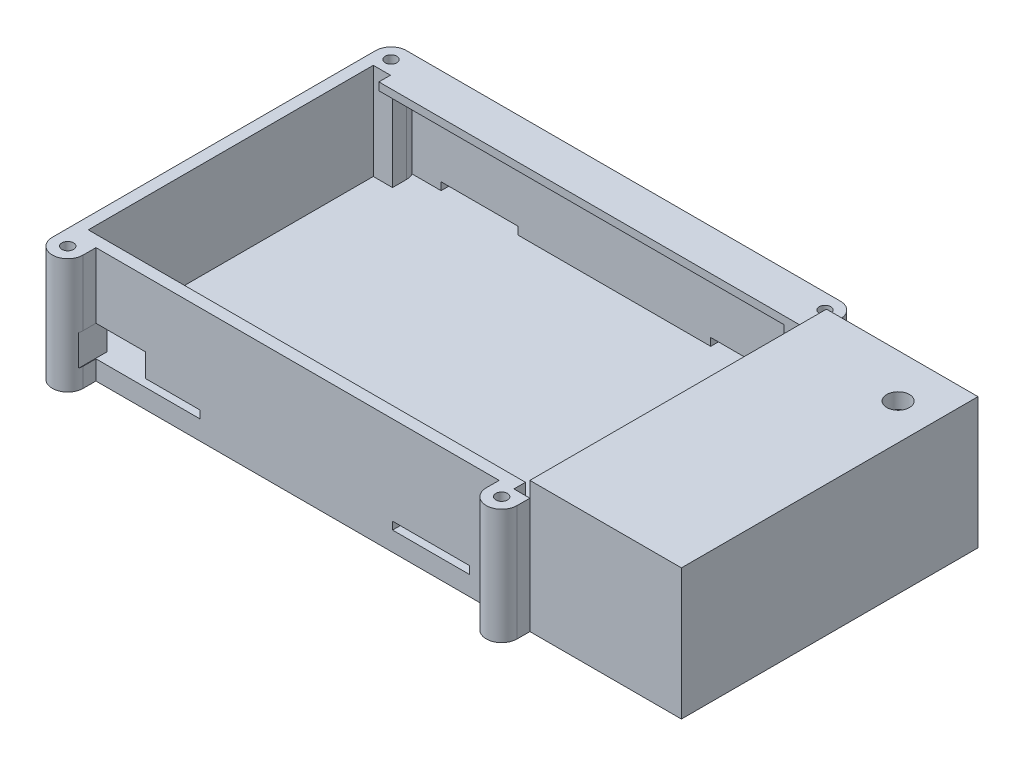
from build123d import *

# Parameters (mm, degrees)
SKETCH1_W           = 160
SKETCH1_H           = 77
BOSS_EXTRUDE1_DEPTH = 5
BOSS_EXTRUDE2_DEPTH = 25
SKETCH3_R           = 1.499999813
SKETCH3_R_2         = 1.5
BOSS_EXTRUDE3_DEPTH = 30
SKETCH5_W           = 39.3418497
SKETCH5_H           = 77
SKETCH5_R           = 2.947381685
BOSS_EXTRUDE5_DEPTH = 4
BOSS_EXTRUDE6_DEPTH = 5
SKETCH9_W           = 112.573012358
SKETCH9_H           = 2
BOSS_EXTRUDE7_DEPTH = 25
CUT_EXTRUDE2_START  = -74
SKETCH7_W           = 13
SKETCH7_H           = 8
CUT_EXTRUDE2_DEPTH  = 119
SKETCH6_W           = 20
SKETCH6_H           = 2
CUT_EXTRUDE1_DEPTH  = 179
SKETCH10_W          = 4
SKETCH10_H          = 3
CUT_EXTRUDE3_DEPTH  = 7
SKETCH11_W          = 105.740519207
SKETCH11_H          = 2
BOSS_EXTRUDE8_DEPTH = 8.609255


with BuildPart() as part:
    # Sketch1 → Boss-Extrude1 (new body)
    with BuildSketch(Plane(origin=(0, 0, 0), x_dir=(1, 0, 0), z_dir=(0, 1, 0))):
        with Locations((-80, -38.5)):
            Rectangle(SKETCH1_W, SKETCH1_H)
    extrude(amount=BOSS_EXTRUDE1_DEPTH)

    # Sketch2 → Boss-Extrude2 (add)
    with BuildSketch(Plane(origin=(0, 5, 0), x_dir=(1, 0, 0), z_dir=(0, 1, 0))):
        Polygon((-160, 0), (-157, 0), (-157, -74), (-3, -74), (-3, -3), (-47.4, -3), (-47.4, 0), (0, 0), (0, -77), (-160, -77), align=None)
    extrude(amount=BOSS_EXTRUDE2_DEPTH)

    # Sketch3 → Boss-Extrude3 (add)
    with BuildSketch(Plane.XZ):
        with BuildLine():
            Line((-160, 77), (-152.006026471, 77))
            Line((-152.006026471, 77), (-152.006026471, 80.326705))
            ThreePointArc((-152.006026471, 80.326705), (-156.003013236, 84.323691764), (-160, 80.326705))
            Line((-160, 80.326705), (-160, 77))
        make_face()
        with Locations((-156.003013236, 80.326705)):
            Circle(SKETCH3_R, mode=Mode.SUBTRACT)
        with BuildLine():
            Line((-47.333694812, 80.326705), (-47.333694812, 77))
            Line((-47.333694812, 77), (-39.3418497, 77))
            Line((-39.3418497, 77), (-39.3418497, 80.326705))
            ThreePointArc((-39.3418497, 80.326705), (-43.337772256, 84.322627556), (-47.333694812, 80.326705))
        make_face()
        with Locations((-43.337772256, 80.326705)):
            Circle(SKETCH3_R_2, mode=Mode.SUBTRACT)
        with BuildLine():
            Line((-160, 0), (-152.006026471, 0))
            Line((-152.006026471, 0), (-152.006026471, -3.613332))
            ThreePointArc((-152.006026471, -3.613332), (-156.003013236, -7.610318764), (-160, -3.613332))
            Line((-160, -3.613332), (-160, 0))
        make_face()
        with Locations((-156.003013236, -3.613332)):
            Circle(SKETCH3_R_2, mode=Mode.SUBTRACT)
        with BuildLine():
            Line((-47.333694812, -3.613332), (-47.333694812, 0))
            Line((-47.333694812, 0), (-39.3418497, 0))
            Line((-39.3418497, 0), (-39.3418497, -3.613332))
            ThreePointArc((-39.3418497, -3.613332), (-43.337772256, -7.609254556), (-47.333694812, -3.613332))
        make_face()
        with Locations((-43.337772256, -3.613332)):
            Circle(SKETCH3_R_2, mode=Mode.SUBTRACT)
    extrude(amount=-BOSS_EXTRUDE3_DEPTH)

    # Sketch5 → Boss-Extrude5 (add)
    with BuildSketch(Plane(origin=(0, 30, 0), x_dir=(1, 0, 0), z_dir=(0, 1, 0))):
        with Locations((-19.67092485, -38.5)):
            Rectangle(SKETCH5_W, SKETCH5_H)
        with Locations((-9.3881, -11.3566)):
            Circle(SKETCH5_R, mode=Mode.SUBTRACT)
    extrude(amount=BOSS_EXTRUDE5_DEPTH)

    # Sketch8 → Boss-Extrude6 (add)
    with BuildSketch(Plane.XZ):
        with BuildLine():
            ThreePointArc((-152.006026471, -3.613332), (-153.144295011, -6.4068304), (-155.910784614, -7.609254556))
            Line((-155.910784614, -7.609254556), (-43.337772256, -7.609254556))
            ThreePointArc((-43.337772256, -7.609254556), (-46.163316193, -6.438875937), (-47.333694812, -3.613332))
            Line((-47.333694812, -3.613332), (-47.333694812, 0))
            Line((-47.333694812, 0), (-152.006026471, 0))
            Line((-152.006026471, 0), (-152.006026471, -3.613332))
        make_face()
    extrude(amount=-BOSS_EXTRUDE6_DEPTH)

    # Sketch9 → Boss-Extrude7 (add)
    with BuildSketch(Plane(origin=(0, 5, 0), x_dir=(1, 0, 0), z_dir=(0, 1, 0))):
        with Locations((-99.624278435, 6.609254556)):
            Rectangle(SKETCH9_W, SKETCH9_H)
    extrude(amount=BOSS_EXTRUDE7_DEPTH)

    # Sketch7 → Cut-Extrude2 (cut)
    with BuildSketch(Plane(origin=(0, 0, 0), x_dir=(-1, 0, 0), z_dir=(0, 0, -1)).offset(CUT_EXTRUDE2_START)):
        with Locations((145.6418497, 9)):
            Rectangle(SKETCH7_W, SKETCH7_H)
    extrude(amount=-CUT_EXTRUDE2_DEPTH, mode=Mode.SUBTRACT)

    # Sketch6 → Cut-Extrude1 (cut)
    with BuildSketch(Plane.XY.offset(77)):
        with Locations((-135, 6)):
            Rectangle(SKETCH6_W, SKETCH6_H)
        with Locations((-65, 6)):
            Rectangle(SKETCH6_W, SKETCH6_H)
    extrude(amount=-CUT_EXTRUDE1_DEPTH, mode=Mode.SUBTRACT)

    # Sketch10 → Cut-Extrude3 (cut)
    with BuildSketch(Plane(origin=(0, 30, 0), x_dir=(1, 0, 0), z_dir=(0, 1, 0))):
        with Locations((-41.4918497, -75.5)):
            Rectangle(SKETCH10_W, SKETCH10_H)
    extrude(amount=-CUT_EXTRUDE3_DEPTH, mode=Mode.SUBTRACT)

    # Sketch11 → Boss-Extrude8 (add)
    with BuildSketch(Plane.XY.offset(-5.609254556)):
        with Locations((-99.669778561, 29)):
            Rectangle(SKETCH11_W, SKETCH11_H)
    extrude(amount=BOSS_EXTRUDE8_DEPTH)


solid = part.part
